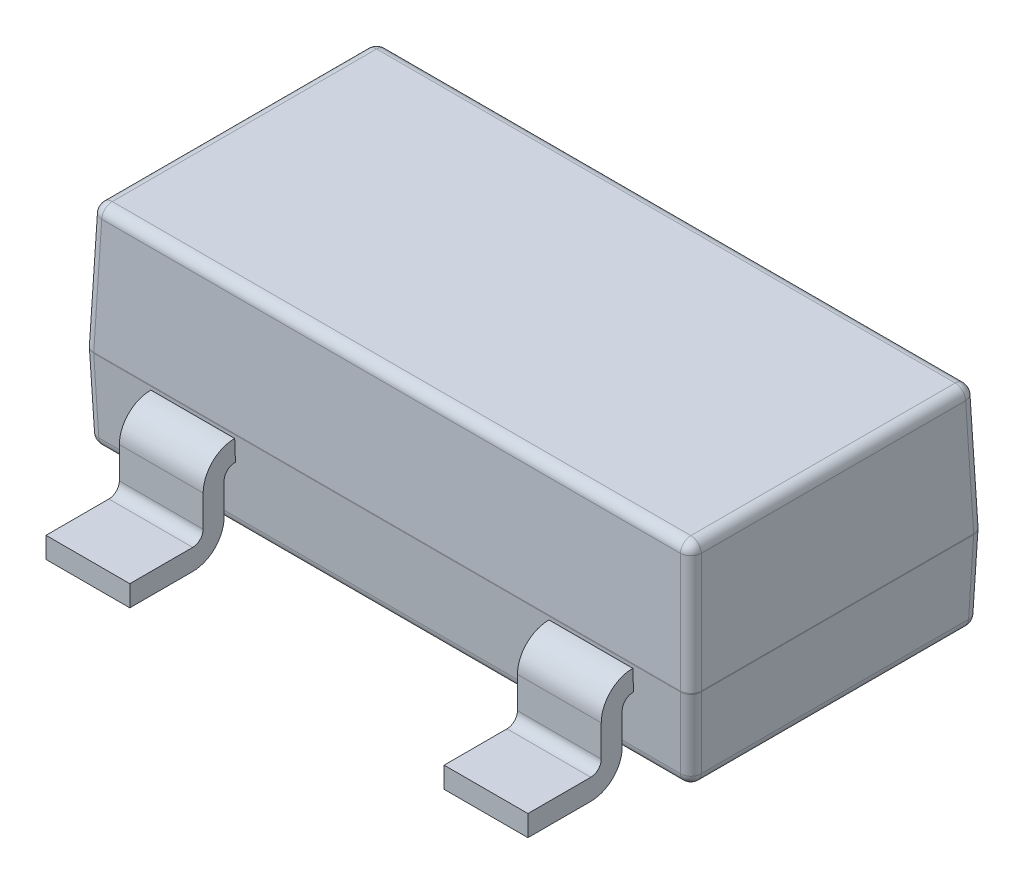
from build123d import *

# Parameters (mm, degrees)
SKETCH1_W                = 2.9
SKETCH1_H                = 1.4
EXTRUDE1_DEPTH           = 0.6
EXTRUDE1_TAPER           = 2
EXTRUDE1_OTHER_WAY_DEPTH = 0.4
EXTRUDE1_OTHER_WAY_TAPER = 2
FILLET1_R                = 0.05
SKETCH4_W                = 0.4
SKETCH4_H                = 0.1
SKETCH6_W                = 0.4
SKETCH6_H                = 0.1
LPATTERN1_COUNT          = 2
LPATTERN1_PITCH          = 1.9


with BuildPart() as part:
    # Sketch1 → Extrude1 (new body)
    with BuildSketch(Plane(origin=(0, 0, 0), x_dir=(1, 0, 0), z_dir=(0, 1, 0))):
        with Locations((-0.022336989, 0.003590633)):
            Rectangle(SKETCH1_W, SKETCH1_H)
    extrude(amount=EXTRUDE1_DEPTH, taper=EXTRUDE1_TAPER)

    # Sketch1 → Extrude1 other way (add)
    with BuildSketch(Plane(origin=(0, 0, 0), x_dir=(1, 0, 0), z_dir=(0, 1, 0))):
        with Locations((-0.022336989, 0.003590633)):
            Rectangle(SKETCH1_W, SKETCH1_H)
    extrude(amount=-EXTRUDE1_OTHER_WAY_DEPTH, taper=EXTRUDE1_OTHER_WAY_TAPER)

    # Fillet1
    fillet1_edges = [part.edges().sort_by_distance(p)[0] for p in [
        (1.406710549, 0.6, -0.003590633),
        (-1.458368681, -0.4, -0.003590633),
        (-1.465352835, -0.2, 0.689425213),
        (-0.022336989, -0.4, -0.689622325),
        (-1.465352835, -0.2, -0.696606479),
        (1.413694703, -0.4, -0.003590633),
        (-0.022336989, 0.6, -0.682638171),
        (1.420678857, -0.2, -0.696606479),
        (-0.022336989, -0.4, 0.682441059),
        (1.420678857, -0.2, 0.689425213),
        (-1.451384528, 0.6, -0.003590633),
        (-0.022336989, 0, -0.703590633),
        (1.427663011, 0, -0.003590633),
        (-0.022336989, 0, 0.696409367),
        (-1.472336989, 0, -0.003590633),
        (-0.022336989, 0.6, 0.675456905),
        (-1.461860758, 0.3, -0.693114402),
        (1.41718678, 0.3, -0.693114402),
        (1.41718678, 0.3, 0.685933136),
        (-1.461860758, 0.3, 0.685933136),
    ]]
    fillet(fillet1_edges, radius=FILLET1_R)

    # Sweep2: sweep along a path in Sketch2
    with BuildLine(Plane(origin=(0, 0, 0), x_dir=(0, 0, -1), z_dir=(1, 0, 0))) as sweep2_path:
        Line((0, -0.071744975), (0.703590633, -0.071744975))
        ThreePointArc((0.703590633, -0.071744975), (0.774301311, -0.101034297), (0.803590633, -0.171744975))
        Line((0.803590633, -0.171744975), (0.803590633, -0.321744975))
        ThreePointArc((0.803590633, -0.321744975), (0.832879955, -0.392455653), (0.903590633, -0.421744975))
        Line((0.903590633, -0.421744975), (1.203590633, -0.421744975))
    # Sketch4 → Sweep2 (sweep)
    with BuildSketch(Plane.XY):
        with Locations((0, -0.071744975)):
            Rectangle(SKETCH4_W, SKETCH4_H)
    sweep(path=sweep2_path.line)

    # Sweep3: sweep along a path in Sketch5
    with BuildLine(Plane(origin=(0.95, 0, 0), x_dir=(0, 0, -1), z_dir=(1, 0, 0))) as sweep3_path:
        Line((0.084564348, -0.068255025), (-0.696409367, -0.068255025))
        ThreePointArc((-0.696409367, -0.068255025), (-0.767120045, -0.097544347), (-0.796409367, -0.168255025))
        Line((-0.796409367, -0.168255025), (-0.796409367, -0.318255025))
        ThreePointArc((-0.796409367, -0.318255025), (-0.825698689, -0.388965703), (-0.896409367, -0.418255025))
        Line((-0.896409367, -0.418255025), (-1.196409367, -0.418255025))
    # Sketch6 → Sweep3 (sweep)
    with BuildSketch(Plane.XY):
        with Locations((0.95, -0.068255025)):
            Rectangle(SKETCH6_W, SKETCH6_H)
    sweep3 = sweep(path=sweep3_path.line)

    # LPattern1: Sweep3 ×2
    with Locations(*[(-i * LPATTERN1_PITCH, 0, 0) for i in range(1, LPATTERN1_COUNT)]):
        add(sweep3)


solid = part.part
